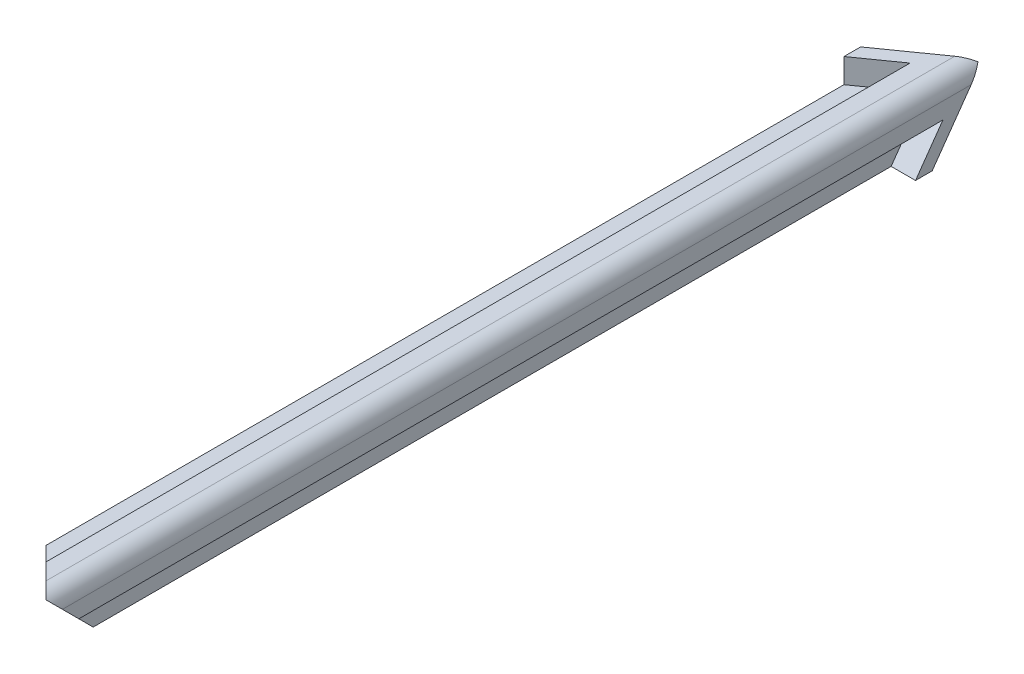
from build123d import *

# Parameters (mm, degrees)
SKETCH7_W               = 4.7625
SKETCH7_H               = 2.12122512
BOSS_EXTRUDE2_DEPTH     = 130.175
SKETCH8_W               = 2.12122512
SKETCH8_H               = 4.7625
BOSS_EXTRUDE3_DEPTH     = 130.175
BOSS_EXTRUDE4_DEPTH     = 130.175
CUT_EXTRUDE6_DEPTH      = 245.098438966
CUT_EXTRUDE6_DEPTH_BACK = 245.098438966
CUT_EXTRUDE7_DEPTH      = 219.920809905
CUT_EXTRUDE7_DEPTH_BACK = 219.920809905


with BuildPart() as part:
    # Sketch7 → Boss-Extrude2 (new, symmetric)
    with BuildSketch(Plane.XY):
        with Locations((-4.92125, -2.560612608)):
            Rectangle(SKETCH7_W, SKETCH7_H)
    extrude(amount=BOSS_EXTRUDE2_DEPTH, both=True)

    # Sketch8 → Boss-Extrude3 (add, symmetric)
    with BuildSketch(Plane.XY):
        with Locations((-2.560612608, -4.92125)):
            Rectangle(SKETCH8_W, SKETCH8_H)
    extrude(amount=BOSS_EXTRUDE3_DEPTH, both=True)

    # Sketch11 → Boss-Extrude4 (add, symmetric)
    with BuildSketch(Plane.XY):
        with BuildLine():
            Line((-2.54, 1.500000048), (-2.54, -1.500000048))
            Line((-2.54, -1.500000048), (-7.3025, -1.500000048))
            Line((-7.3025, -1.500000048), (-7.3025, -3.621225168))
            Line((-7.3025, -3.621225168), (-5.866289198, -3.621225168))
            Line((-5.866289198, -3.621225168), (-3.621225168, -5.866289198))
            Line((-3.621225168, -5.866289198), (-3.621225168, -7.3025))
            Line((-3.621225168, -7.3025), (-1.500000048, -7.3025))
            Line((-1.500000048, -7.3025), (-1.500000048, -2.54))
            Line((-1.500000048, -2.54), (1.500000048, -2.54))
            Line((1.500000048, -2.54), (1.500000048, -0.519999976))
            ThreePointArc((1.500000048, -0.519999976), (0.908355739, 0.908355739), (-0.519999976, 1.500000048))
            Line((-0.519999976, 1.500000048), (-2.54, 1.500000048))
        make_face()
    extrude(amount=BOSS_EXTRUDE4_DEPTH, both=True)

    # Sketch18 → Cut-Extrude6 (cut, two sides: drawn at the far end of the back side and taken through both)
    with BuildSketch(Plane(origin=(0, 0, 113.704878), x_dir=(-0.7071067811865466, 0.7071067811865485, 0), z_dir=(-0.5773502691896266, -0.577350269189625, -0.577350269189626)).offset(-CUT_EXTRUDE6_DEPTH_BACK)):
        Polygon((0, 0), (63.5, 36.661742094), (0, -73.323484187), (-63.5, 36.661742094), align=None)
    extrude(amount=CUT_EXTRUDE6_DEPTH + CUT_EXTRUDE6_DEPTH_BACK, mode=Mode.SUBTRACT)

    # Sketch19 → Cut-Extrude7 (cut, two sides: drawn at the far end of the back side and taken through both)
    with BuildSketch(Plane(origin=(-66.606775424, -160.802980576, 0), x_dir=(0.7071067811865466, -0.7071067811865485, 0), z_dir=(0.7071067811865485, 0.7071067811865466, 0)).offset(-CUT_EXTRUDE7_DEPTH_BACK)):
        Polygon((-66.606775424, 0), (187.393224576, -254), (187.393224576, 254), (-320.606775424, 254), (-320.606775424, -254), align=None)
    extrude(amount=CUT_EXTRUDE7_DEPTH + CUT_EXTRUDE7_DEPTH_BACK, mode=Mode.SUBTRACT)

    # Sweep1: sweep along a curve in space
    with BuildLine() as sweep1_path:
        Line((-7.3025, -1.500000048, 4.102987064), (-2.54, -1.500000048, 0.735391018))
    # Sketch20 → Sweep1 (sweep)
    with BuildSketch(Plane.ZY.offset(2.54)):
        Polygon((4.906903198, 1.5), (4.906903198, -1.500000048), (0.735391018, -1.500000048), (2.85671143, 1.500000048), align=None)
    sweep(path=sweep1_path.line)

    # Sweep2: sweep along a curve in space
    with BuildLine() as sweep2_path:
        Line((-1.500000048, -2.54, 0.735391018), (-1.500000048, -7.3025, 4.102987064))
    # Sketch21 → Sweep2 (sweep)
    with BuildSketch(Plane.XZ.offset(2.54)):
        Polygon((-1.500000048, 4.906903198), (1.500000048, 4.906903198), (1.500000048, 2.85671143), (-1.500000048, 0.735391018), align=None)
    sweep(path=sweep2_path.line)


solid = part.part
